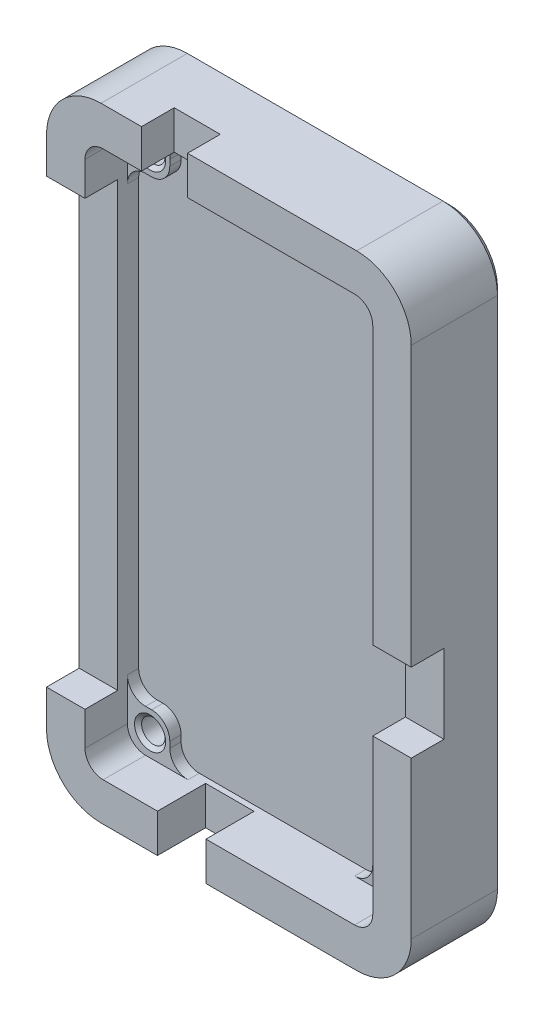
from build123d import *

# Parameters (mm, degrees)
SKETCH1_W                             = 60.198
SKETCH1_H                             = 102.87
BOSS_EXTRUDE1_DEPTH                   = 0.0254
BOSS_EXTRUDE1_DEPTH_BACK              = 6.35
SKETCH1_3_W                           = 60.198
SKETCH1_3_H                           = 102.87
SKETCH1_3_W_2                         = 47.498
SKETCH1_3_H_2                         = 90.17
BOSS_EXTRUDE2_DEPTH                   = 8.89
SKETCH2_W                             = 7
SKETCH2_H                             = 7
BOSS_EXTRUDE3_DEPTH                   = 1.8646
F_24_0_152_DIAMETER_HOLE1_D           = 3.8608
F_24_0_152_DIAMETER_HOLE1_DEPTH       = 5.08
F_24_0_152_DIAMETER_HOLE1_CSINK_D     = 5.1308
F_24_0_152_DIAMETER_HOLE1_CSINK_ANGLE = 100
F_24_0_152_DIAMETER_HOLE1_TIP         = 1.159901339
SKETCH6_W                             = 6.35
SKETCH6_H                             = 73.025
SKETCH6_W_2                           = 8.000000002
SKETCH6_H_2                           = 6.35
SKETCH6_W_3                           = 7.60000004
SKETCH6_H_3                           = 12.999999908
CUT_EXTRUDE1_DEPTH                    = 5.4
FILLET1_R                             = 3
FILLET2_R                             = 9
CHAMFER1_SIZE                         = 1
SKETCH9_W                             = 25.4
SKETCH9_H                             = 63.5
CUT_EXTRUDE2_DEPTH                    = 4.445
BOSS_EXTRUDE4_REACH                   = 32.099
BOSS_EXTRUDE4_DIRECTION_2_REACH       = 32.099
BOSS_EXTRUDE5_DEPTH                   = 12.573
BOSS_EXTRUDE5_DEPTH_BACK              = 12.573
CUT_EXTRUDE3_START                    = -1.254
SKETCH11_R                            = 5.01
CUT_EXTRUDE3_DEPTH                    = 2.454
SKETCH12_R                            = 5.51
CUT_EXTRUDE4_DEPTH                    = 1.2
SKETCH13_W                            = 8.000000002
SKETCH13_H                            = 6.35
CUT_EXTRUDE5_DEPTH                    = 2.54
CHAMFER2_SIZE                         = 0.399999962
CHAMFER3_SIZE                         = 0.508
SKETCH14_R                            = 5.264
CUT_EXTRUDE6_DEPTH                    = 1
CHAMFER4_SIZE                         = 0.2


with BuildPart() as part:
    # Sketch1 → Boss-Extrude1 (new body, two sides)
    with BuildSketch(Plane.XY) as boss_extrude1_sk:
        Rectangle(SKETCH1_W, SKETCH1_H)
    extrude(amount=BOSS_EXTRUDE1_DEPTH)
    extrude(boss_extrude1_sk.sketch, amount=-BOSS_EXTRUDE1_DEPTH_BACK)

    # Sketch1_3 → Boss-Extrude2 (add)
    with BuildSketch(Plane.XY):
        Rectangle(SKETCH1_3_W, SKETCH1_3_H)
        Rectangle(SKETCH1_3_W_2, SKETCH1_3_H_2, mode=Mode.SUBTRACT)
    extrude(amount=BOSS_EXTRUDE2_DEPTH)

    # Sketch2 → Boss-Extrude3 (add)
    with BuildSketch(Plane.XY.offset(0.0254)):
        with Locations((20.249, 41.585)):
            Rectangle(SKETCH2_W, SKETCH2_H)
        with Locations((20.249, -41.585)):
            Rectangle(SKETCH2_W, SKETCH2_H)
        with Locations((-20.249, -41.585)):
            Rectangle(SKETCH2_W, SKETCH2_H)
        with Locations((-20.249, 41.585)):
            Rectangle(SKETCH2_W, SKETCH2_H)
    extrude(amount=BOSS_EXTRUDE3_DEPTH)

    # 24 _0.152_ Diameter Hole1
    with Locations(Plane(origin=(-20, 41.5, 1.89000003), x_dir=(1, 0, 0), z_dir=(0, 0, 1))):
        with Locations((0, 0), (40, 0), (40, -83), (0, -83)):
            CounterSinkHole(F_24_0_152_DIAMETER_HOLE1_D / 2, F_24_0_152_DIAMETER_HOLE1_CSINK_D / 2, depth=F_24_0_152_DIAMETER_HOLE1_DEPTH, counter_sink_angle=F_24_0_152_DIAMETER_HOLE1_CSINK_ANGLE)
            with Locations((0, 0, -(F_24_0_152_DIAMETER_HOLE1_DEPTH + F_24_0_152_DIAMETER_HOLE1_TIP / 2))):  # 118° drill point
                Cone(0, F_24_0_152_DIAMETER_HOLE1_D / 2, F_24_0_152_DIAMETER_HOLE1_TIP, mode=Mode.SUBTRACT)

    # Sketch6 → Cut-Extrude1 (cut)
    with BuildSketch(Plane.XY.offset(8.89)):
        with Locations((-26.924, 0)):
            Rectangle(SKETCH6_W, SKETCH6_H)
        with Locations((-7.782174936, -48.26)):
            Rectangle(SKETCH6_W_2, SKETCH6_H_2)
        with Locations((-10.614000108, 48.26)):
            Rectangle(SKETCH6_W_3, SKETCH6_H_2)
        with Locations((26.924, -10.071789928)):
            Rectangle(SKETCH6_W, SKETCH6_H_3)
    extrude(amount=-CUT_EXTRUDE1_DEPTH, mode=Mode.SUBTRACT)

    # Fillet1
    fillet1_edges = [part.edges().sort_by_distance(p)[0] for p in [
        (-16.749, 45.085, 0.9577),
        (-23.749, 38.085, 0.9577),
        (-16.749, 38.085, 0.9577),
        (-23.749, -45.085, 5.39),
        (23.749, -45.085, 5.39),
        (23.749, 45.085, 5.39),
        (-23.749, 45.085, 5.39),
        (23.749, 38.085, 0.9577),
        (16.749, 38.085, 0.9577),
        (16.749, 45.085, 0.9577),
        (23.749, -38.085, 0.9577),
        (16.749, -45.085, 0.9577),
        (16.749, -38.085, 0.9577),
        (-23.749, -38.085, 0.9577),
        (-16.749, -38.085, 0.9577),
        (-16.749, -45.085, 0.9577),
    ]]
    fillet(fillet1_edges, radius=FILLET1_R)

    # Fillet2
    fillet2_edges = [part.edges().sort_by_distance(p)[0] for p in [
        (30.099, 51.435, 1.27),
        (-30.099, 51.435, 1.27),
        (-30.099, -51.435, 1.27),
        (30.099, -51.435, 1.27),
    ]]
    fillet(fillet2_edges, radius=FILLET2_R)

    # Chamfer1
    chamfer1_edges = [part.edges().sort_by_distance(p)[0] for p in [
        (0, 51.435, -6.35),
        (30.099, 0, -6.35),
        (0, -51.435, -6.35),
        (-30.099, 0, -6.35),
        (-27.462961031, 48.798961031, -6.35),
        (-27.462961031, -48.798961031, -6.35),
        (27.462961031, -48.798961031, -6.35),
        (27.462961031, 48.798961031, -6.35),
    ]]
    chamfer(chamfer1_edges, length=CHAMFER1_SIZE)

    # Sketch9 → Cut-Extrude2 (cut)
    with BuildSketch(Plane(origin=(0, 0, -6.35), x_dir=(-1, 0, 0), z_dir=(0, 0, -1))):
        with Locations((0, -6.35)):
            Rectangle(SKETCH9_W, SKETCH9_H)
    extrude(amount=-CUT_EXTRUDE2_DEPTH, mode=Mode.SUBTRACT)

    # Sketch10 → Boss-Extrude4 (add, up to next)
    with BuildSketch(Plane(origin=(0, 0, 0), x_dir=(0, 0, -1), z_dir=(1, 0, 0)), mode=Mode.PRIVATE) as boss_extrude4_sk1:
        Polygon((4.7625, 20.450664817), (4.7625, 25.4), (1.905, 25.4), align=None)
    boss_extrude4_tool1 = extrude(boss_extrude4_sk1.sketch, amount=BOSS_EXTRUDE4_REACH, mode=Mode.PRIVATE) - part.part
    add(boss_extrude4_tool1.solids().sort_by_distance((0, 23.750222, -3.81))[0])

    # Sketch10 → Boss-Extrude4 direction 2 (add, up to next)
    with BuildSketch(Plane(origin=(0, 0, 0), x_dir=(0, 0, -1), z_dir=(1, 0, 0)), mode=Mode.PRIVATE) as boss_extrude4_direction_2_sk1:
        Polygon((4.7625, 20.450664817), (4.7625, 25.4), (1.905, 25.4), align=None)
    boss_extrude4_direction_2_tool1 = extrude(boss_extrude4_direction_2_sk1.sketch, amount=-BOSS_EXTRUDE4_DIRECTION_2_REACH, mode=Mode.PRIVATE) - part.part
    add(boss_extrude4_direction_2_tool1.solids().sort_by_distance((0, 23.750222, -3.81))[0])


with BuildPart() as body_2:
    # Sketch10_3 → Boss-Extrude5 (new body, two sides)
    with BuildSketch(Plane(origin=(0, 0, 0), x_dir=(0, 0, -1), z_dir=(1, 0, 0))) as boss_extrude5_sk:
        Polygon((2.159, 24.452059095), (4.7625, 19.942664817), (4.7625, -12.7), (2.159, -12.7), align=None)
    extrude(amount=BOSS_EXTRUDE5_DEPTH)
    extrude(boss_extrude5_sk.sketch, amount=-BOSS_EXTRUDE5_DEPTH_BACK)


with BuildPart() as cut_extrude3_tool:
    # Sketch11 → Cut-Extrude3 (new body)
    with BuildSketch(Plane.XY.offset(-1.905).offset(CUT_EXTRUDE3_START)):
        with Locations((0, -6.35)):
            Circle(SKETCH11_R)
        with Locations((0, 6.35)):
            Circle(SKETCH11_R)
    extrude(amount=CUT_EXTRUDE3_DEPTH)


with BuildPart() as part_1:
    add(part.part)

    # Cut-Extrude3: cut by cut_extrude3_tool
    add(cut_extrude3_tool.part, mode=Mode.SUBTRACT)

    # Sketch12 → Cut-Extrude4 (cut)
    with BuildSketch(Plane(origin=(0, 0, -1.905), x_dir=(-1, 0, 0), z_dir=(0, 0, -1))):
        with Locations((0, 6.35)):
            Circle(SKETCH12_R)
        with Locations((0, -6.35)):
            Circle(SKETCH12_R)
    extrude(amount=-CUT_EXTRUDE4_DEPTH, mode=Mode.SUBTRACT)

    # Sketch13 → Cut-Extrude5 (cut)
    with BuildSketch(Plane.XY.offset(3.490000132)):
        with Locations((-7.782174936, -48.26)):
            Rectangle(SKETCH13_W, SKETCH13_H)
    extrude(amount=-CUT_EXTRUDE5_DEPTH, mode=Mode.SUBTRACT)

    # Chamfer2
    chamfer2_edges = [part_1.edges().sort_by_distance(p)[0] for p in [
        (-12.7, -6.35, -6.35),
        (0, 25.4, -6.35),
        (12.7, -6.35, -6.35),
        (0, -38.1, -6.35),
    ]]
    chamfer(chamfer2_edges, length=CHAMFER2_SIZE)


with BuildPart() as body_2_1:
    add(body_2.part)

    # Cut-Extrude3: cut by cut_extrude3_tool
    add(cut_extrude3_tool.part, mode=Mode.SUBTRACT)

    # Chamfer3
    chamfer3_edges = [body_2_1.edges().sort_by_distance(p)[0] for p in [
        (12.573, 3.621332409, -4.7625),
        (12.573, 5.876029547, -2.159),
        (-12.573, 3.621332409, -4.7625),
        (-12.573, 5.876029547, -2.159),
    ]]
    chamfer(chamfer3_edges, length=CHAMFER3_SIZE)

    # Sketch14 → Cut-Extrude6 (cut)
    with BuildSketch(Plane.XY.offset(-2.159)):
        with Locations((0, 6.35)):
            Circle(SKETCH14_R)
        with Locations((0, -6.35)):
            Circle(SKETCH14_R)
    extrude(amount=-CUT_EXTRUDE6_DEPTH, mode=Mode.SUBTRACT)

    # Chamfer4
    chamfer4_edges = [body_2_1.edges().sort_by_distance(p)[0] for p in [
        (-5.264, 6.35, -2.159),
        (-5.264, -6.35, -2.159),
    ]]
    chamfer(chamfer4_edges, length=CHAMFER4_SIZE)


solid = Compound([part_1.part, body_2_1.part])
